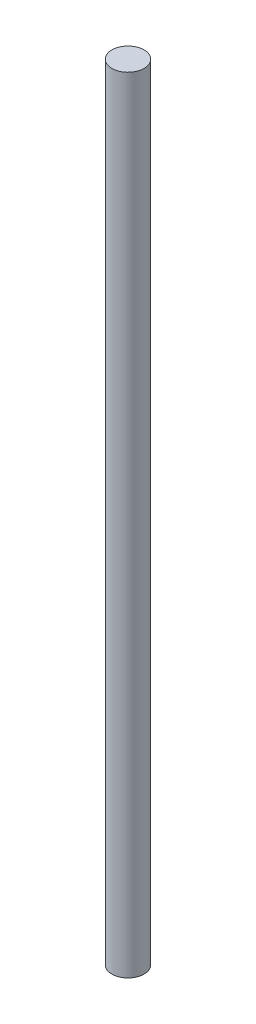
from build123d import *

# Parameters (mm, degrees)
SKETCH1_R           = 4
BOSS_EXTRUDE1_DEPTH = 195


with BuildPart() as part:
    # Sketch1 → Boss-Extrude1 (new body)
    with BuildSketch(Plane(origin=(0, 0, 0), x_dir=(1, 0, 0), z_dir=(0, 1, 0))):
        Circle(SKETCH1_R)
    extrude(amount=BOSS_EXTRUDE1_DEPTH)


solid = part.part
